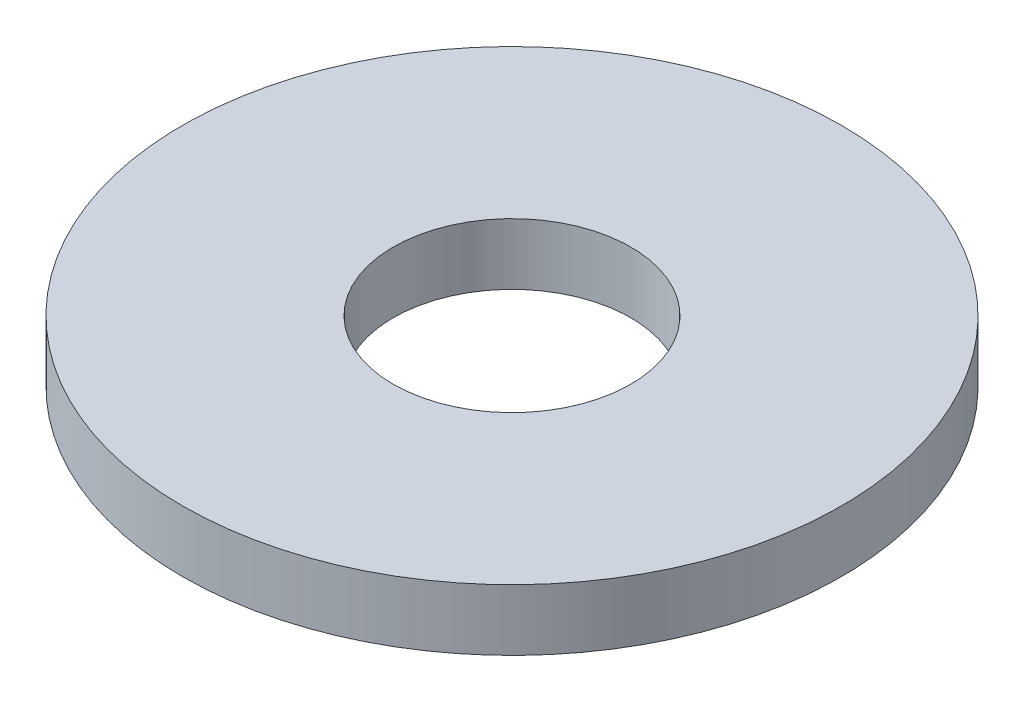
from build123d import *

# Parameters (mm, degrees)
SKETCH1_R           = 8.875
SKETCH1_R_2         = 3.2
BOSS_EXTRUDE1_DEPTH = 1.65


with BuildPart() as part:
    # Sketch1 → Boss-Extrude1 (new body)
    with BuildSketch(Plane(origin=(0, 0, 0), x_dir=(1, 0, 0), z_dir=(0, 1, 0))):
        Circle(SKETCH1_R)
        Circle(SKETCH1_R_2, mode=Mode.SUBTRACT)
    extrude(amount=BOSS_EXTRUDE1_DEPTH)


solid = part.part
